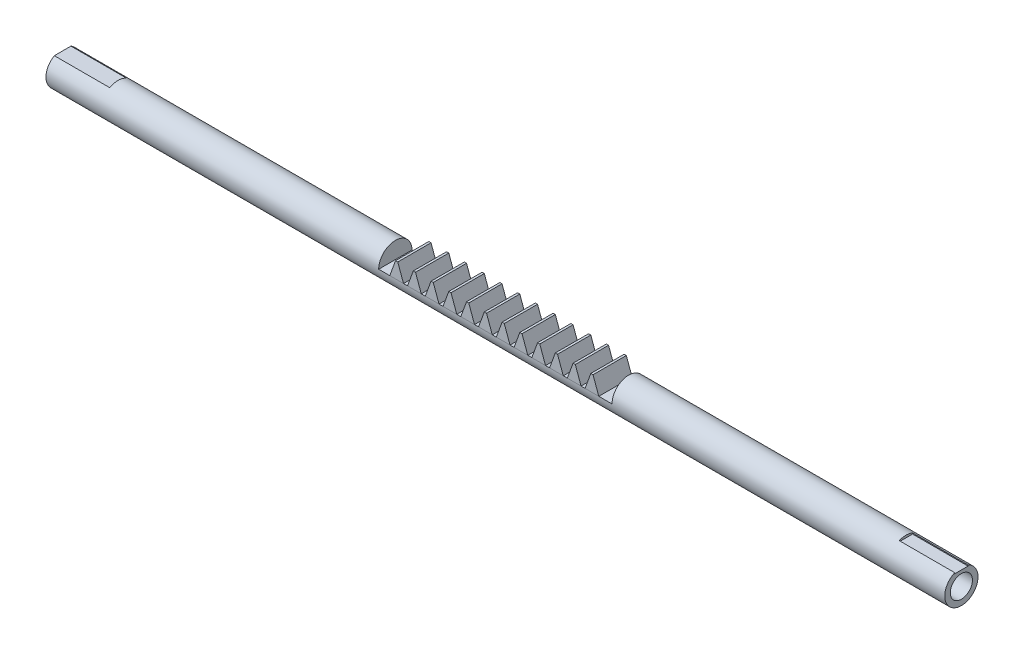
from build123d import *

# Parameters (mm, degrees)
SKETCH1_R               = 0.375
BOSS_EXTRUDE1_DEPTH     = 20.25
SKETCH3_R               = 0.25
CUT_EXTRUDE1_DEPTH      = 6.5
SKETCH4_R               = 0.25
CUT_EXTRUDE2_DEPTH      = 6.5
SKETCH5_W               = 0.3
SKETCH5_H               = 0.1
CUT_EXTRUDE3_DEPTH      = 1.25
SKETCH6_W               = 0.5
SKETCH6_H               = 0.1
CUT_EXTRUDE4_DEPTH      = 1.25
SKETCH7_W               = 5.25772593
SKETCH7_H               = 0.43012496
CUT_EXTRUDE5_DEPTH      = 1.375
CUT_EXTRUDE5_DEPTH_BACK = 1.375
BOSS_EXTRUDE2_DEPTH     = 0.375
LPATTERN1_COUNT         = 12
LPATTERN1_PITCH         = 0.4


with BuildPart() as part:
    # Sketch1 → Boss-Extrude1 (new body)
    with BuildSketch(Plane(origin=(0, 0, 0), x_dir=(0, 0, -1), z_dir=(1, 0, 0))):
        Circle(SKETCH1_R)
    extrude(amount=BOSS_EXTRUDE1_DEPTH)

    # Sketch3 → Cut-Extrude1 (cut)
    with BuildSketch(Plane(origin=(0, 0, 0), x_dir=(0, 0, -1), z_dir=(1, 0, 0))):
        Circle(SKETCH3_R)
    extrude(amount=CUT_EXTRUDE1_DEPTH, mode=Mode.SUBTRACT)

    # Sketch4 → Cut-Extrude2 (cut)
    with BuildSketch(Plane(origin=(20.25, 0, 0), x_dir=(0, 0, -1), z_dir=(1, 0, 0))):
        Circle(SKETCH4_R)
    extrude(amount=-CUT_EXTRUDE2_DEPTH, mode=Mode.SUBTRACT)

    # Sketch5 → Cut-Extrude3 (cut)
    with BuildSketch(Plane(origin=(20.25, 0, 0), x_dir=(0, 0, -1), z_dir=(1, 0, 0))):
        with Locations((0, 0.371911734)):
            Rectangle(SKETCH5_W, SKETCH5_H)
    extrude(amount=-CUT_EXTRUDE3_DEPTH, mode=Mode.SUBTRACT)

    # Sketch6 → Cut-Extrude4 (cut)
    with BuildSketch(Plane(origin=(0, 0, 0), x_dir=(0, 0, -1), z_dir=(1, 0, 0))):
        with Locations((0, 0.375)):
            Rectangle(SKETCH6_W, SKETCH6_H)
    extrude(amount=CUT_EXTRUDE4_DEPTH, mode=Mode.SUBTRACT)

    # Sketch7 → Cut-Extrude5 (cut, two sides)
    with BuildSketch(Plane.XY) as cut_extrude5_sk:
        with Locations((10.125, 0.21506248)):
            Rectangle(SKETCH7_W, SKETCH7_H)
    extrude(amount=CUT_EXTRUDE5_DEPTH, mode=Mode.SUBTRACT)
    extrude(cut_extrude5_sk.sketch, amount=-CUT_EXTRUDE5_DEPTH_BACK, mode=Mode.SUBTRACT)

    # Sketch8 → Boss-Extrude2 (add, symmetric)
    with BuildSketch(Plane.XY):
        Polygon((7.746137035, 0), (7.875912836, 0.356556082), (7.925912836, 0.356556082), (8.055688636, 0), align=None)
    boss_extrude2 = extrude(amount=BOSS_EXTRUDE2_DEPTH, both=True)

    # LPattern1: Boss-Extrude2 ×12
    with Locations(*[(i * LPATTERN1_PITCH, 0, 0) for i in range(1, LPATTERN1_COUNT)]):
        add(boss_extrude2)


solid = part.part
